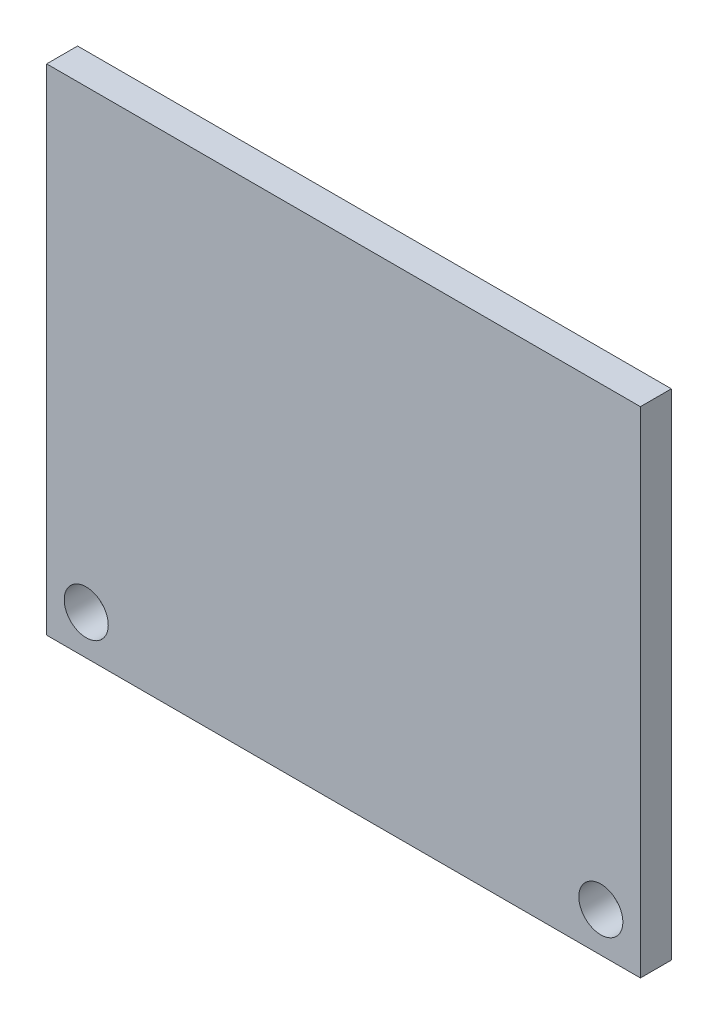
from build123d import *

# Parameters (mm, degrees)
SKETCH1_W                 = 30.48
SKETCH1_H                 = 25.4
BOSS_EXTRUDE1_DEPTH       = 1.5875
F_2_CLEARANCE_HOLE1_D     = 2.2606
F_2_CLEARANCE_HOLE1_DEPTH = 1.5885


with BuildPart() as part:
    # Sketch1 → Boss-Extrude1 (new body)
    with BuildSketch(Plane.XY):
        Rectangle(SKETCH1_W, SKETCH1_H)
    extrude(amount=BOSS_EXTRUDE1_DEPTH)

    # #2 Clearance Hole1
    with Locations(Plane.XY.offset(1.5875)):
        with Locations((-13.208, -10.668)):
            f_2_clearance_hole1 = Hole(F_2_CLEARANCE_HOLE1_D / 2, depth=F_2_CLEARANCE_HOLE1_DEPTH)

    # Mirror1: #2 Clearance Hole1 across plane
    add(f_2_clearance_hole1.mirror(Plane(origin=(0, 0, 0), x_dir=(0, 0, 1), z_dir=(1, 0, 0))), mode=Mode.SUBTRACT)


solid = part.part
